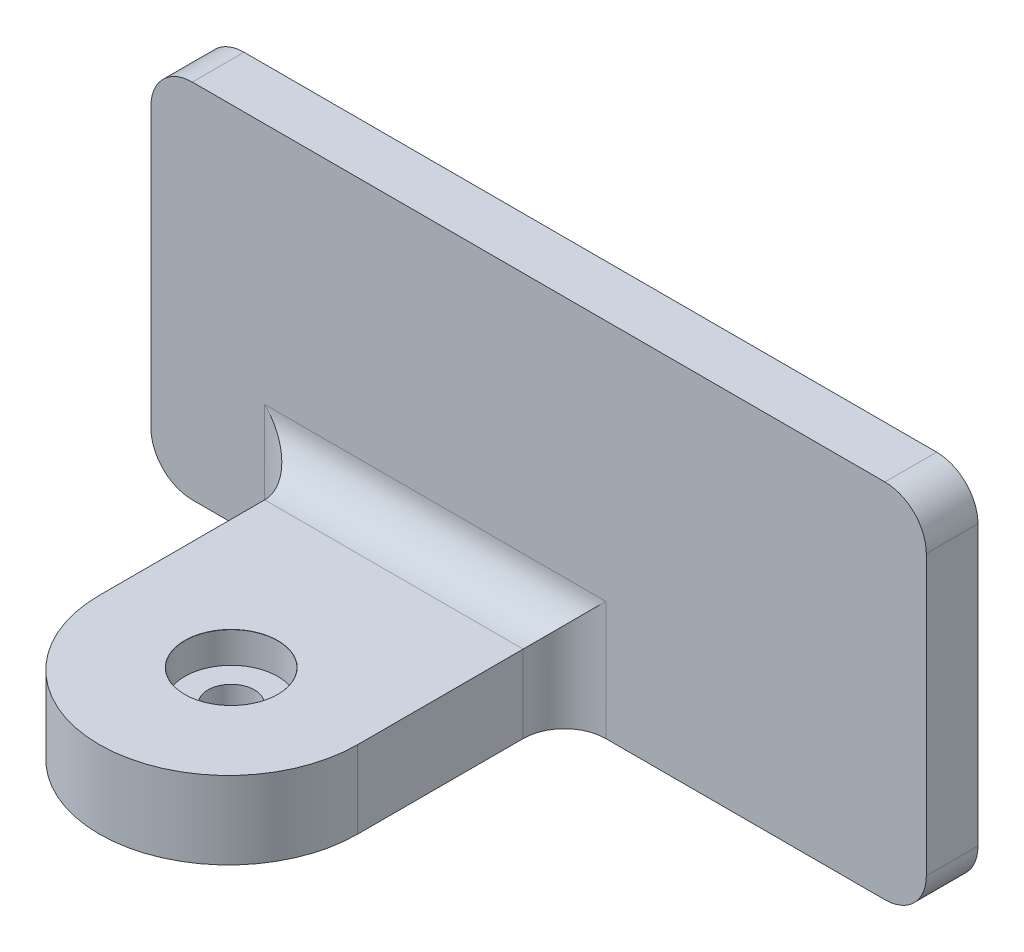
from build123d import *

# Parameters (mm, degrees)
SKETCH1_W           = 150
SKETCH1_H           = 70
BOSS_EXTRUDE1_DEPTH = 10
BOSS_EXTRUDE2_DEPTH = 15
FILLET1_R           = 8
FILLET2_R           = 8
FILLET3_R           = 8
FILLET4_R           = 8
FILLET5_R           = 8
FILLET6_R           = 8
FILLET11_R          = 8


with BuildPart() as part:
    # Sketch1 → Boss-Extrude1 (new body)
    with BuildSketch(Plane.XY):
        with Locations((75, 35)):
            Rectangle(SKETCH1_W, SKETCH1_H)
    extrude(amount=BOSS_EXTRUDE1_DEPTH)

    # Sketch2 → Boss-Extrude2 (add)
    with BuildSketch(Plane(origin=(0, 0, 0), x_dir=(-1, 0, 0), z_dir=(0, -1, 0))):
        with BuildLine():
            Line((-80, -50), (-80, 0))
            Line((-80, 0), (-30, 0))
            Line((-30, 0), (-30, -50))
            ThreePointArc((-30, -50), (-55, -75), (-80, -50))
        make_face()
    extrude(amount=-BOSS_EXTRUDE2_DEPTH)

    # Fillet1
    fillet1_edges = [part.edges().sort_by_distance(p)[0] for p in [
        (80, 7.5, 10),
    ]]
    fillet(fillet1_edges, radius=FILLET1_R)

    # Fillet2
    fillet2_edges = [part.edges().sort_by_distance(p)[0] for p in [
        (55, 15, 10),
    ]]
    fillet(fillet2_edges, radius=FILLET2_R)

    # Fillet3
    fillet3_edges = [part.edges().sort_by_distance(p)[0] for p in [
        (30, 7.5, 10),
    ]]
    fillet(fillet3_edges, radius=FILLET3_R)

    # Fillet4
    fillet4_edges = [part.edges().sort_by_distance(p)[0] for p in [
        (150, 70, 5),
    ]]
    fillet(fillet4_edges, radius=FILLET4_R)

    # Fillet5
    fillet5_edges = [part.edges().sort_by_distance(p)[0] for p in [
        (150, 0, 5),
    ]]
    fillet(fillet5_edges, radius=FILLET5_R)

    # Fillet6
    fillet6_edges = [part.edges().sort_by_distance(p)[0] for p in [
        (0, 70, 5),
    ]]
    fillet(fillet6_edges, radius=FILLET6_R)

    # Fillet11
    fillet11_edges = [part.edges().sort_by_distance(p)[0] for p in [
        (0, 0, 5),
    ]]
    fillet(fillet11_edges, radius=FILLET11_R)

    # Sketch4 → CBORE for M8 Pan Head Machine Screw1 (revolve, cut)
    with BuildSketch(Plane(origin=(54.842028673, 15, 49.313893032), x_dir=(0, 0, 1), z_dir=(1, 0, 0))):
        Polygon((0, 0), (0, 15), (4.5, 15), (4.5, 6), (9, 6), (9, 0.020977491), (9.025, 0), align=None)
    revolve(axis=Axis((54.842028673, 21.35, 49.313893032), (0, -1, 0)), mode=Mode.SUBTRACT)


solid = part.part
